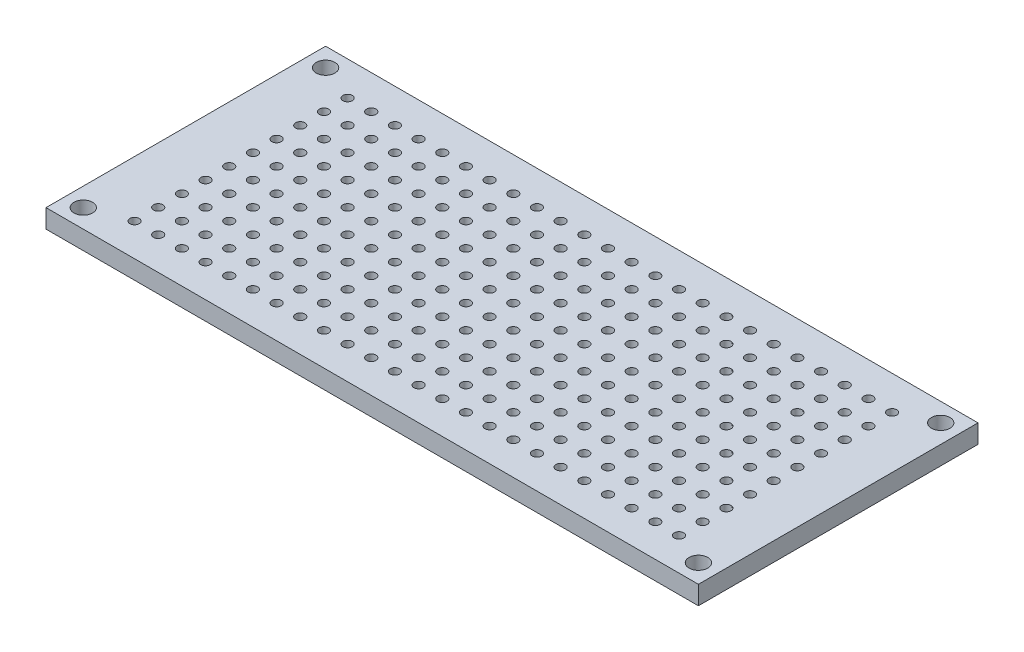
from build123d import *

# Parameters (mm, degrees)
SKETCH_1_W      = 70
SKETCH_1_H      = 30
SKETCH_1_R      = 1
SKETCH_1_R_2    = 0.5
EXTRUDE_1_DEPTH = 2


with BuildPart() as part:
    # Эскиз1 → Бобышка-Вытянуть1 (new body)
    with BuildSketch(Plane(origin=(0, 0, 0), x_dir=(1, 0, 0), z_dir=(0, 1, 0))):
        Rectangle(SKETCH_1_W, SKETCH_1_H)
        with Locations((-33, 13)):
            Circle(SKETCH_1_R, mode=Mode.SUBTRACT)
        with Locations((-33, -13)):
            Circle(SKETCH_1_R, mode=Mode.SUBTRACT)
        with Locations((33, 13)):
            Circle(SKETCH_1_R, mode=Mode.SUBTRACT)
        with Locations((33, -13)):
            Circle(SKETCH_1_R, mode=Mode.SUBTRACT)
        with Locations((-29, -11.5)):
            Circle(SKETCH_1_R_2, mode=Mode.SUBTRACT)
        with Locations((-26.46, -11.5)):
            Circle(SKETCH_1_R_2, mode=Mode.SUBTRACT)
        with Locations((-23.92, -11.5)):
            Circle(SKETCH_1_R_2, mode=Mode.SUBTRACT)
        with Locations((-21.38, -11.5)):
            Circle(SKETCH_1_R_2, mode=Mode.SUBTRACT)
        with Locations((-18.84, -11.5)):
            Circle(SKETCH_1_R_2, mode=Mode.SUBTRACT)
        with Locations((-16.3, -11.5)):
            Circle(SKETCH_1_R_2, mode=Mode.SUBTRACT)
        with Locations((-13.76, -11.5)):
            Circle(SKETCH_1_R_2, mode=Mode.SUBTRACT)
        with Locations((-11.22, -11.5)):
            Circle(SKETCH_1_R_2, mode=Mode.SUBTRACT)
        with Locations((-8.68, -11.5)):
            Circle(SKETCH_1_R_2, mode=Mode.SUBTRACT)
        with Locations((-6.14, -11.5)):
            Circle(SKETCH_1_R_2, mode=Mode.SUBTRACT)
        with Locations((-3.6, -11.5)):
            Circle(SKETCH_1_R_2, mode=Mode.SUBTRACT)
        with Locations((-1.06, -11.5)):
            Circle(SKETCH_1_R_2, mode=Mode.SUBTRACT)
        with Locations((1.48, -11.5)):
            Circle(SKETCH_1_R_2, mode=Mode.SUBTRACT)
        with Locations((4.02, -11.5)):
            Circle(SKETCH_1_R_2, mode=Mode.SUBTRACT)
        with Locations((6.56, -11.5)):
            Circle(SKETCH_1_R_2, mode=Mode.SUBTRACT)
        with Locations((9.1, -11.5)):
            Circle(SKETCH_1_R_2, mode=Mode.SUBTRACT)
        with Locations((11.64, -11.5)):
            Circle(SKETCH_1_R_2, mode=Mode.SUBTRACT)
        with Locations((14.18, -11.5)):
            Circle(SKETCH_1_R_2, mode=Mode.SUBTRACT)
        with Locations((16.72, -11.5)):
            Circle(SKETCH_1_R_2, mode=Mode.SUBTRACT)
        with Locations((19.26, -11.5)):
            Circle(SKETCH_1_R_2, mode=Mode.SUBTRACT)
        with Locations((21.8, -11.5)):
            Circle(SKETCH_1_R_2, mode=Mode.SUBTRACT)
        with Locations((24.34, -11.5)):
            Circle(SKETCH_1_R_2, mode=Mode.SUBTRACT)
        with Locations((26.88, -11.5)):
            Circle(SKETCH_1_R_2, mode=Mode.SUBTRACT)
        with Locations((29.42, -11.5)):
            Circle(SKETCH_1_R_2, mode=Mode.SUBTRACT)
        with Locations((-26.46, -8.96)):
            Circle(SKETCH_1_R_2, mode=Mode.SUBTRACT)
        with Locations((-23.92, -8.96)):
            Circle(SKETCH_1_R_2, mode=Mode.SUBTRACT)
        with Locations((-21.38, -8.96)):
            Circle(SKETCH_1_R_2, mode=Mode.SUBTRACT)
        with Locations((-18.84, -8.96)):
            Circle(SKETCH_1_R_2, mode=Mode.SUBTRACT)
        with Locations((-16.3, -8.96)):
            Circle(SKETCH_1_R_2, mode=Mode.SUBTRACT)
        with Locations((-13.76, -8.96)):
            Circle(SKETCH_1_R_2, mode=Mode.SUBTRACT)
        with Locations((-11.22, -8.96)):
            Circle(SKETCH_1_R_2, mode=Mode.SUBTRACT)
        with Locations((-8.68, -8.96)):
            Circle(SKETCH_1_R_2, mode=Mode.SUBTRACT)
        with Locations((-6.14, -8.96)):
            Circle(SKETCH_1_R_2, mode=Mode.SUBTRACT)
        with Locations((-3.6, -8.96)):
            Circle(SKETCH_1_R_2, mode=Mode.SUBTRACT)
        with Locations((-1.06, -8.96)):
            Circle(SKETCH_1_R_2, mode=Mode.SUBTRACT)
        with Locations((1.48, -8.96)):
            Circle(SKETCH_1_R_2, mode=Mode.SUBTRACT)
        with Locations((4.02, -8.96)):
            Circle(SKETCH_1_R_2, mode=Mode.SUBTRACT)
        with Locations((6.56, -8.96)):
            Circle(SKETCH_1_R_2, mode=Mode.SUBTRACT)
        with Locations((9.1, -8.96)):
            Circle(SKETCH_1_R_2, mode=Mode.SUBTRACT)
        with Locations((11.64, -8.96)):
            Circle(SKETCH_1_R_2, mode=Mode.SUBTRACT)
        with Locations((14.18, -8.96)):
            Circle(SKETCH_1_R_2, mode=Mode.SUBTRACT)
        with Locations((16.72, -8.96)):
            Circle(SKETCH_1_R_2, mode=Mode.SUBTRACT)
        with Locations((19.26, -8.96)):
            Circle(SKETCH_1_R_2, mode=Mode.SUBTRACT)
        with Locations((21.8, -8.96)):
            Circle(SKETCH_1_R_2, mode=Mode.SUBTRACT)
        with Locations((24.34, -8.96)):
            Circle(SKETCH_1_R_2, mode=Mode.SUBTRACT)
        with Locations((26.88, -8.96)):
            Circle(SKETCH_1_R_2, mode=Mode.SUBTRACT)
        with Locations((29.42, -8.96)):
            Circle(SKETCH_1_R_2, mode=Mode.SUBTRACT)
        with Locations((-26.46, -6.42)):
            Circle(SKETCH_1_R_2, mode=Mode.SUBTRACT)
        with Locations((-23.92, -6.42)):
            Circle(SKETCH_1_R_2, mode=Mode.SUBTRACT)
        with Locations((-21.38, -6.42)):
            Circle(SKETCH_1_R_2, mode=Mode.SUBTRACT)
        with Locations((-18.84, -6.42)):
            Circle(SKETCH_1_R_2, mode=Mode.SUBTRACT)
        with Locations((-16.3, -6.42)):
            Circle(SKETCH_1_R_2, mode=Mode.SUBTRACT)
        with Locations((-13.76, -6.42)):
            Circle(SKETCH_1_R_2, mode=Mode.SUBTRACT)
        with Locations((-11.22, -6.42)):
            Circle(SKETCH_1_R_2, mode=Mode.SUBTRACT)
        with Locations((-8.68, -6.42)):
            Circle(SKETCH_1_R_2, mode=Mode.SUBTRACT)
        with Locations((-6.14, -6.42)):
            Circle(SKETCH_1_R_2, mode=Mode.SUBTRACT)
        with Locations((-3.6, -6.42)):
            Circle(SKETCH_1_R_2, mode=Mode.SUBTRACT)
        with Locations((-1.06, -6.42)):
            Circle(SKETCH_1_R_2, mode=Mode.SUBTRACT)
        with Locations((1.48, -6.42)):
            Circle(SKETCH_1_R_2, mode=Mode.SUBTRACT)
        with Locations((4.02, -6.42)):
            Circle(SKETCH_1_R_2, mode=Mode.SUBTRACT)
        with Locations((6.56, -6.42)):
            Circle(SKETCH_1_R_2, mode=Mode.SUBTRACT)
        with Locations((9.1, -6.42)):
            Circle(SKETCH_1_R_2, mode=Mode.SUBTRACT)
        with Locations((11.64, -6.42)):
            Circle(SKETCH_1_R_2, mode=Mode.SUBTRACT)
        with Locations((14.18, -6.42)):
            Circle(SKETCH_1_R_2, mode=Mode.SUBTRACT)
        with Locations((16.72, -6.42)):
            Circle(SKETCH_1_R_2, mode=Mode.SUBTRACT)
        with Locations((19.26, -6.42)):
            Circle(SKETCH_1_R_2, mode=Mode.SUBTRACT)
        with Locations((21.8, -6.42)):
            Circle(SKETCH_1_R_2, mode=Mode.SUBTRACT)
        with Locations((24.34, -6.42)):
            Circle(SKETCH_1_R_2, mode=Mode.SUBTRACT)
        with Locations((26.88, -6.42)):
            Circle(SKETCH_1_R_2, mode=Mode.SUBTRACT)
        with Locations((29.42, -6.42)):
            Circle(SKETCH_1_R_2, mode=Mode.SUBTRACT)
        with Locations((-26.46, -3.88)):
            Circle(SKETCH_1_R_2, mode=Mode.SUBTRACT)
        with Locations((-23.92, -3.88)):
            Circle(SKETCH_1_R_2, mode=Mode.SUBTRACT)
        with Locations((-21.38, -3.88)):
            Circle(SKETCH_1_R_2, mode=Mode.SUBTRACT)
        with Locations((-18.84, -3.88)):
            Circle(SKETCH_1_R_2, mode=Mode.SUBTRACT)
        with Locations((-16.3, -3.88)):
            Circle(SKETCH_1_R_2, mode=Mode.SUBTRACT)
        with Locations((-13.76, -3.88)):
            Circle(SKETCH_1_R_2, mode=Mode.SUBTRACT)
        with Locations((-11.22, -3.88)):
            Circle(SKETCH_1_R_2, mode=Mode.SUBTRACT)
        with Locations((-8.68, -3.88)):
            Circle(SKETCH_1_R_2, mode=Mode.SUBTRACT)
        with Locations((-6.14, -3.88)):
            Circle(SKETCH_1_R_2, mode=Mode.SUBTRACT)
        with Locations((-3.6, -3.88)):
            Circle(SKETCH_1_R_2, mode=Mode.SUBTRACT)
        with Locations((-1.06, -3.88)):
            Circle(SKETCH_1_R_2, mode=Mode.SUBTRACT)
        with Locations((1.48, -3.88)):
            Circle(SKETCH_1_R_2, mode=Mode.SUBTRACT)
        with Locations((4.02, -3.88)):
            Circle(SKETCH_1_R_2, mode=Mode.SUBTRACT)
        with Locations((6.56, -3.88)):
            Circle(SKETCH_1_R_2, mode=Mode.SUBTRACT)
        with Locations((9.1, -3.88)):
            Circle(SKETCH_1_R_2, mode=Mode.SUBTRACT)
        with Locations((11.64, -3.88)):
            Circle(SKETCH_1_R_2, mode=Mode.SUBTRACT)
        with Locations((14.18, -3.88)):
            Circle(SKETCH_1_R_2, mode=Mode.SUBTRACT)
        with Locations((16.72, -3.88)):
            Circle(SKETCH_1_R_2, mode=Mode.SUBTRACT)
        with Locations((19.26, -3.88)):
            Circle(SKETCH_1_R_2, mode=Mode.SUBTRACT)
        with Locations((21.8, -3.88)):
            Circle(SKETCH_1_R_2, mode=Mode.SUBTRACT)
        with Locations((24.34, -3.88)):
            Circle(SKETCH_1_R_2, mode=Mode.SUBTRACT)
        with Locations((26.88, -3.88)):
            Circle(SKETCH_1_R_2, mode=Mode.SUBTRACT)
        with Locations((29.42, -3.88)):
            Circle(SKETCH_1_R_2, mode=Mode.SUBTRACT)
        with Locations((-26.46, -1.34)):
            Circle(SKETCH_1_R_2, mode=Mode.SUBTRACT)
        with Locations((-23.92, -1.34)):
            Circle(SKETCH_1_R_2, mode=Mode.SUBTRACT)
        with Locations((-21.38, -1.34)):
            Circle(SKETCH_1_R_2, mode=Mode.SUBTRACT)
        with Locations((-18.84, -1.34)):
            Circle(SKETCH_1_R_2, mode=Mode.SUBTRACT)
        with Locations((-16.3, -1.34)):
            Circle(SKETCH_1_R_2, mode=Mode.SUBTRACT)
        with Locations((-13.76, -1.34)):
            Circle(SKETCH_1_R_2, mode=Mode.SUBTRACT)
        with Locations((-11.22, -1.34)):
            Circle(SKETCH_1_R_2, mode=Mode.SUBTRACT)
        with Locations((-8.68, -1.34)):
            Circle(SKETCH_1_R_2, mode=Mode.SUBTRACT)
        with Locations((-6.14, -1.34)):
            Circle(SKETCH_1_R_2, mode=Mode.SUBTRACT)
        with Locations((-3.6, -1.34)):
            Circle(SKETCH_1_R_2, mode=Mode.SUBTRACT)
        with Locations((-1.06, -1.34)):
            Circle(SKETCH_1_R_2, mode=Mode.SUBTRACT)
        with Locations((1.48, -1.34)):
            Circle(SKETCH_1_R_2, mode=Mode.SUBTRACT)
        with Locations((4.02, -1.34)):
            Circle(SKETCH_1_R_2, mode=Mode.SUBTRACT)
        with Locations((6.56, -1.34)):
            Circle(SKETCH_1_R_2, mode=Mode.SUBTRACT)
        with Locations((9.1, -1.34)):
            Circle(SKETCH_1_R_2, mode=Mode.SUBTRACT)
        with Locations((11.64, -1.34)):
            Circle(SKETCH_1_R_2, mode=Mode.SUBTRACT)
        with Locations((14.18, -1.34)):
            Circle(SKETCH_1_R_2, mode=Mode.SUBTRACT)
        with Locations((16.72, -1.34)):
            Circle(SKETCH_1_R_2, mode=Mode.SUBTRACT)
        with Locations((19.26, -1.34)):
            Circle(SKETCH_1_R_2, mode=Mode.SUBTRACT)
        with Locations((21.8, -1.34)):
            Circle(SKETCH_1_R_2, mode=Mode.SUBTRACT)
        with Locations((24.34, -1.34)):
            Circle(SKETCH_1_R_2, mode=Mode.SUBTRACT)
        with Locations((26.88, -1.34)):
            Circle(SKETCH_1_R_2, mode=Mode.SUBTRACT)
        with Locations((29.42, -1.34)):
            Circle(SKETCH_1_R_2, mode=Mode.SUBTRACT)
        with Locations((-26.46, 1.2)):
            Circle(SKETCH_1_R_2, mode=Mode.SUBTRACT)
        with Locations((-23.92, 1.2)):
            Circle(SKETCH_1_R_2, mode=Mode.SUBTRACT)
        with Locations((-21.38, 1.2)):
            Circle(SKETCH_1_R_2, mode=Mode.SUBTRACT)
        with Locations((-18.84, 1.2)):
            Circle(SKETCH_1_R_2, mode=Mode.SUBTRACT)
        with Locations((-16.3, 1.2)):
            Circle(SKETCH_1_R_2, mode=Mode.SUBTRACT)
        with Locations((-13.76, 1.2)):
            Circle(SKETCH_1_R_2, mode=Mode.SUBTRACT)
        with Locations((-11.22, 1.2)):
            Circle(SKETCH_1_R_2, mode=Mode.SUBTRACT)
        with Locations((-8.68, 1.2)):
            Circle(SKETCH_1_R_2, mode=Mode.SUBTRACT)
        with Locations((-6.14, 1.2)):
            Circle(SKETCH_1_R_2, mode=Mode.SUBTRACT)
        with Locations((-3.6, 1.2)):
            Circle(SKETCH_1_R_2, mode=Mode.SUBTRACT)
        with Locations((-1.06, 1.2)):
            Circle(SKETCH_1_R_2, mode=Mode.SUBTRACT)
        with Locations((1.48, 1.2)):
            Circle(SKETCH_1_R_2, mode=Mode.SUBTRACT)
        with Locations((4.02, 1.2)):
            Circle(SKETCH_1_R_2, mode=Mode.SUBTRACT)
        with Locations((6.56, 1.2)):
            Circle(SKETCH_1_R_2, mode=Mode.SUBTRACT)
        with Locations((9.1, 1.2)):
            Circle(SKETCH_1_R_2, mode=Mode.SUBTRACT)
        with Locations((11.64, 1.2)):
            Circle(SKETCH_1_R_2, mode=Mode.SUBTRACT)
        with Locations((14.18, 1.2)):
            Circle(SKETCH_1_R_2, mode=Mode.SUBTRACT)
        with Locations((16.72, 1.2)):
            Circle(SKETCH_1_R_2, mode=Mode.SUBTRACT)
        with Locations((19.26, 1.2)):
            Circle(SKETCH_1_R_2, mode=Mode.SUBTRACT)
        with Locations((21.8, 1.2)):
            Circle(SKETCH_1_R_2, mode=Mode.SUBTRACT)
        with Locations((24.34, 1.2)):
            Circle(SKETCH_1_R_2, mode=Mode.SUBTRACT)
        with Locations((26.88, 1.2)):
            Circle(SKETCH_1_R_2, mode=Mode.SUBTRACT)
        with Locations((29.42, 1.2)):
            Circle(SKETCH_1_R_2, mode=Mode.SUBTRACT)
        with Locations((-26.46, 3.74)):
            Circle(SKETCH_1_R_2, mode=Mode.SUBTRACT)
        with Locations((-23.92, 3.74)):
            Circle(SKETCH_1_R_2, mode=Mode.SUBTRACT)
        with Locations((-21.38, 3.74)):
            Circle(SKETCH_1_R_2, mode=Mode.SUBTRACT)
        with Locations((-18.84, 3.74)):
            Circle(SKETCH_1_R_2, mode=Mode.SUBTRACT)
        with Locations((-16.3, 3.74)):
            Circle(SKETCH_1_R_2, mode=Mode.SUBTRACT)
        with Locations((-13.76, 3.74)):
            Circle(SKETCH_1_R_2, mode=Mode.SUBTRACT)
        with Locations((-11.22, 3.74)):
            Circle(SKETCH_1_R_2, mode=Mode.SUBTRACT)
        with Locations((-8.68, 3.74)):
            Circle(SKETCH_1_R_2, mode=Mode.SUBTRACT)
        with Locations((-6.14, 3.74)):
            Circle(SKETCH_1_R_2, mode=Mode.SUBTRACT)
        with Locations((-3.6, 3.74)):
            Circle(SKETCH_1_R_2, mode=Mode.SUBTRACT)
        with Locations((-1.06, 3.74)):
            Circle(SKETCH_1_R_2, mode=Mode.SUBTRACT)
        with Locations((1.48, 3.74)):
            Circle(SKETCH_1_R_2, mode=Mode.SUBTRACT)
        with Locations((4.02, 3.74)):
            Circle(SKETCH_1_R_2, mode=Mode.SUBTRACT)
        with Locations((6.56, 3.74)):
            Circle(SKETCH_1_R_2, mode=Mode.SUBTRACT)
        with Locations((9.1, 3.74)):
            Circle(SKETCH_1_R_2, mode=Mode.SUBTRACT)
        with Locations((11.64, 3.74)):
            Circle(SKETCH_1_R_2, mode=Mode.SUBTRACT)
        with Locations((14.18, 3.74)):
            Circle(SKETCH_1_R_2, mode=Mode.SUBTRACT)
        with Locations((16.72, 3.74)):
            Circle(SKETCH_1_R_2, mode=Mode.SUBTRACT)
        with Locations((19.26, 3.74)):
            Circle(SKETCH_1_R_2, mode=Mode.SUBTRACT)
        with Locations((21.8, 3.74)):
            Circle(SKETCH_1_R_2, mode=Mode.SUBTRACT)
        with Locations((24.34, 3.74)):
            Circle(SKETCH_1_R_2, mode=Mode.SUBTRACT)
        with Locations((26.88, 3.74)):
            Circle(SKETCH_1_R_2, mode=Mode.SUBTRACT)
        with Locations((29.42, 3.74)):
            Circle(SKETCH_1_R_2, mode=Mode.SUBTRACT)
        with Locations((-26.46, 6.28)):
            Circle(SKETCH_1_R_2, mode=Mode.SUBTRACT)
        with Locations((-23.92, 6.28)):
            Circle(SKETCH_1_R_2, mode=Mode.SUBTRACT)
        with Locations((-21.38, 6.28)):
            Circle(SKETCH_1_R_2, mode=Mode.SUBTRACT)
        with Locations((-18.84, 6.28)):
            Circle(SKETCH_1_R_2, mode=Mode.SUBTRACT)
        with Locations((-16.3, 6.28)):
            Circle(SKETCH_1_R_2, mode=Mode.SUBTRACT)
        with Locations((-13.76, 6.28)):
            Circle(SKETCH_1_R_2, mode=Mode.SUBTRACT)
        with Locations((-11.22, 6.28)):
            Circle(SKETCH_1_R_2, mode=Mode.SUBTRACT)
        with Locations((-8.68, 6.28)):
            Circle(SKETCH_1_R_2, mode=Mode.SUBTRACT)
        with Locations((-6.14, 6.28)):
            Circle(SKETCH_1_R_2, mode=Mode.SUBTRACT)
        with Locations((-3.6, 6.28)):
            Circle(SKETCH_1_R_2, mode=Mode.SUBTRACT)
        with Locations((-1.06, 6.28)):
            Circle(SKETCH_1_R_2, mode=Mode.SUBTRACT)
        with Locations((1.48, 6.28)):
            Circle(SKETCH_1_R_2, mode=Mode.SUBTRACT)
        with Locations((4.02, 6.28)):
            Circle(SKETCH_1_R_2, mode=Mode.SUBTRACT)
        with Locations((6.56, 6.28)):
            Circle(SKETCH_1_R_2, mode=Mode.SUBTRACT)
        with Locations((9.1, 6.28)):
            Circle(SKETCH_1_R_2, mode=Mode.SUBTRACT)
        with Locations((11.64, 6.28)):
            Circle(SKETCH_1_R_2, mode=Mode.SUBTRACT)
        with Locations((14.18, 6.28)):
            Circle(SKETCH_1_R_2, mode=Mode.SUBTRACT)
        with Locations((16.72, 6.28)):
            Circle(SKETCH_1_R_2, mode=Mode.SUBTRACT)
        with Locations((19.26, 6.28)):
            Circle(SKETCH_1_R_2, mode=Mode.SUBTRACT)
        with Locations((21.8, 6.28)):
            Circle(SKETCH_1_R_2, mode=Mode.SUBTRACT)
        with Locations((24.34, 6.28)):
            Circle(SKETCH_1_R_2, mode=Mode.SUBTRACT)
        with Locations((26.88, 6.28)):
            Circle(SKETCH_1_R_2, mode=Mode.SUBTRACT)
        with Locations((29.42, 6.28)):
            Circle(SKETCH_1_R_2, mode=Mode.SUBTRACT)
        with Locations((-26.46, 8.82)):
            Circle(SKETCH_1_R_2, mode=Mode.SUBTRACT)
        with Locations((-23.92, 8.82)):
            Circle(SKETCH_1_R_2, mode=Mode.SUBTRACT)
        with Locations((-21.38, 8.82)):
            Circle(SKETCH_1_R_2, mode=Mode.SUBTRACT)
        with Locations((-18.84, 8.82)):
            Circle(SKETCH_1_R_2, mode=Mode.SUBTRACT)
        with Locations((-16.3, 8.82)):
            Circle(SKETCH_1_R_2, mode=Mode.SUBTRACT)
        with Locations((-13.76, 8.82)):
            Circle(SKETCH_1_R_2, mode=Mode.SUBTRACT)
        with Locations((-11.22, 8.82)):
            Circle(SKETCH_1_R_2, mode=Mode.SUBTRACT)
        with Locations((-8.68, 8.82)):
            Circle(SKETCH_1_R_2, mode=Mode.SUBTRACT)
        with Locations((-6.14, 8.82)):
            Circle(SKETCH_1_R_2, mode=Mode.SUBTRACT)
        with Locations((-3.6, 8.82)):
            Circle(SKETCH_1_R_2, mode=Mode.SUBTRACT)
        with Locations((-1.06, 8.82)):
            Circle(SKETCH_1_R_2, mode=Mode.SUBTRACT)
        with Locations((1.48, 8.82)):
            Circle(SKETCH_1_R_2, mode=Mode.SUBTRACT)
        with Locations((4.02, 8.82)):
            Circle(SKETCH_1_R_2, mode=Mode.SUBTRACT)
        with Locations((6.56, 8.82)):
            Circle(SKETCH_1_R_2, mode=Mode.SUBTRACT)
        with Locations((9.1, 8.82)):
            Circle(SKETCH_1_R_2, mode=Mode.SUBTRACT)
        with Locations((11.64, 8.82)):
            Circle(SKETCH_1_R_2, mode=Mode.SUBTRACT)
        with Locations((14.18, 8.82)):
            Circle(SKETCH_1_R_2, mode=Mode.SUBTRACT)
        with Locations((16.72, 8.82)):
            Circle(SKETCH_1_R_2, mode=Mode.SUBTRACT)
        with Locations((19.26, 8.82)):
            Circle(SKETCH_1_R_2, mode=Mode.SUBTRACT)
        with Locations((21.8, 8.82)):
            Circle(SKETCH_1_R_2, mode=Mode.SUBTRACT)
        with Locations((24.34, 8.82)):
            Circle(SKETCH_1_R_2, mode=Mode.SUBTRACT)
        with Locations((26.88, 8.82)):
            Circle(SKETCH_1_R_2, mode=Mode.SUBTRACT)
        with Locations((29.42, 8.82)):
            Circle(SKETCH_1_R_2, mode=Mode.SUBTRACT)
        with Locations((-26.46, 11.36)):
            Circle(SKETCH_1_R_2, mode=Mode.SUBTRACT)
        with Locations((-23.92, 11.36)):
            Circle(SKETCH_1_R_2, mode=Mode.SUBTRACT)
        with Locations((-21.38, 11.36)):
            Circle(SKETCH_1_R_2, mode=Mode.SUBTRACT)
        with Locations((-18.84, 11.36)):
            Circle(SKETCH_1_R_2, mode=Mode.SUBTRACT)
        with Locations((-16.3, 11.36)):
            Circle(SKETCH_1_R_2, mode=Mode.SUBTRACT)
        with Locations((-13.76, 11.36)):
            Circle(SKETCH_1_R_2, mode=Mode.SUBTRACT)
        with Locations((-11.22, 11.36)):
            Circle(SKETCH_1_R_2, mode=Mode.SUBTRACT)
        with Locations((-8.68, 11.36)):
            Circle(SKETCH_1_R_2, mode=Mode.SUBTRACT)
        with Locations((-6.14, 11.36)):
            Circle(SKETCH_1_R_2, mode=Mode.SUBTRACT)
        with Locations((-3.6, 11.36)):
            Circle(SKETCH_1_R_2, mode=Mode.SUBTRACT)
        with Locations((-1.06, 11.36)):
            Circle(SKETCH_1_R_2, mode=Mode.SUBTRACT)
        with Locations((1.48, 11.36)):
            Circle(SKETCH_1_R_2, mode=Mode.SUBTRACT)
        with Locations((4.02, 11.36)):
            Circle(SKETCH_1_R_2, mode=Mode.SUBTRACT)
        with Locations((6.56, 11.36)):
            Circle(SKETCH_1_R_2, mode=Mode.SUBTRACT)
        with Locations((9.1, 11.36)):
            Circle(SKETCH_1_R_2, mode=Mode.SUBTRACT)
        with Locations((11.64, 11.36)):
            Circle(SKETCH_1_R_2, mode=Mode.SUBTRACT)
        with Locations((14.18, 11.36)):
            Circle(SKETCH_1_R_2, mode=Mode.SUBTRACT)
        with Locations((16.72, 11.36)):
            Circle(SKETCH_1_R_2, mode=Mode.SUBTRACT)
        with Locations((19.26, 11.36)):
            Circle(SKETCH_1_R_2, mode=Mode.SUBTRACT)
        with Locations((21.8, 11.36)):
            Circle(SKETCH_1_R_2, mode=Mode.SUBTRACT)
        with Locations((24.34, 11.36)):
            Circle(SKETCH_1_R_2, mode=Mode.SUBTRACT)
        with Locations((26.88, 11.36)):
            Circle(SKETCH_1_R_2, mode=Mode.SUBTRACT)
        with Locations((29.42, 11.36)):
            Circle(SKETCH_1_R_2, mode=Mode.SUBTRACT)
        with Locations((-29, -8.96)):
            Circle(SKETCH_1_R_2, mode=Mode.SUBTRACT)
        with Locations((-29, -6.42)):
            Circle(SKETCH_1_R_2, mode=Mode.SUBTRACT)
        with Locations((-29, -3.88)):
            Circle(SKETCH_1_R_2, mode=Mode.SUBTRACT)
        with Locations((-29, -1.34)):
            Circle(SKETCH_1_R_2, mode=Mode.SUBTRACT)
        with Locations((-29, 1.2)):
            Circle(SKETCH_1_R_2, mode=Mode.SUBTRACT)
        with Locations((-29, 3.74)):
            Circle(SKETCH_1_R_2, mode=Mode.SUBTRACT)
        with Locations((-29, 6.28)):
            Circle(SKETCH_1_R_2, mode=Mode.SUBTRACT)
        with Locations((-29, 8.82)):
            Circle(SKETCH_1_R_2, mode=Mode.SUBTRACT)
        with Locations((-29, 11.36)):
            Circle(SKETCH_1_R_2, mode=Mode.SUBTRACT)
    extrude(amount=EXTRUDE_1_DEPTH)


solid = part.part
